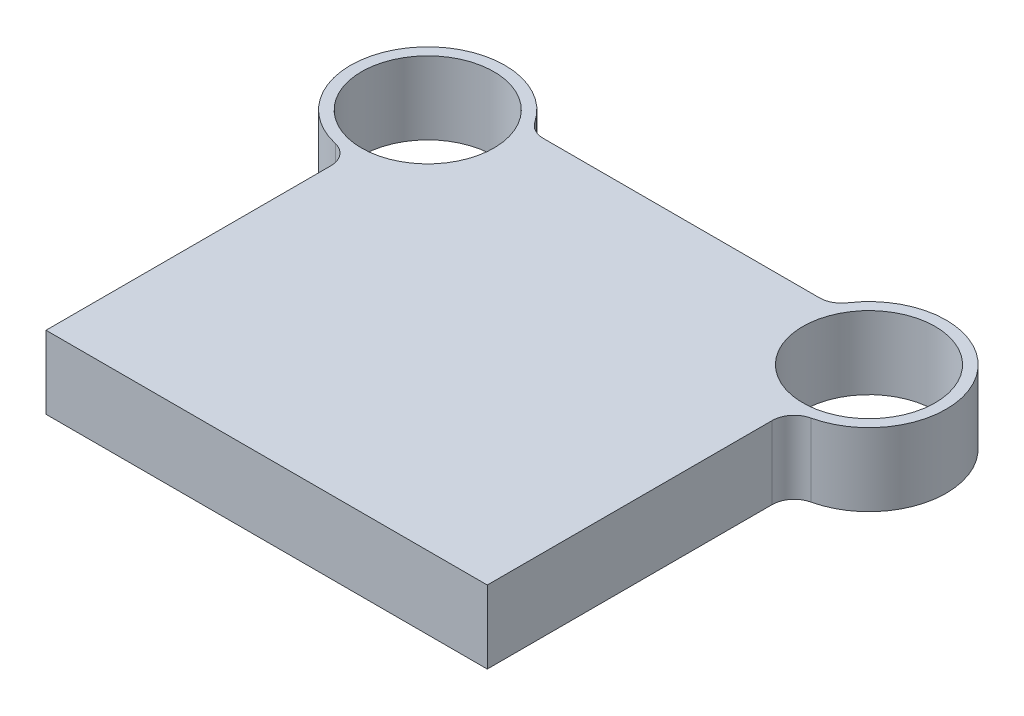
from build123d import *

# Parameters (mm, degrees)
SKETCH1_R           = 30
BOSS_EXTRUDE1_DEPTH = 33
FILLET1_R           = 10


with BuildPart() as part:
    # Sketch1 → Boss-Extrude1 (new body)
    with BuildSketch(Plane(origin=(0, 0, 0), x_dir=(1, 0, 0), z_dir=(0, 1, 0))):
        with BuildLine():
            Line((100, 0), (-100, 0))
            Line((-100, 0), (-100, 138))
            ThreePointArc((-100, 138), (-129.580398915, 191.708286934), (-68.377223398, 188))
            Line((-68.377223398, 188), (68.377223398, 188))
            ThreePointArc((68.377223398, 188), (129.580398915, 191.708286934), (100, 138))
            Line((100, 138), (100, 0))
        make_face()
        with Locations((-100, 173)):
            Circle(SKETCH1_R, mode=Mode.SUBTRACT)
        with Locations((100, 173)):
            Circle(SKETCH1_R, mode=Mode.SUBTRACT)
    extrude(amount=BOSS_EXTRUDE1_DEPTH)

    # Fillet1
    fillet1_edges = [part.edges().sort_by_distance(p)[0] for p in [
        (-100, 16.5, -138),
        (-68.377223398, 16.5, -188),
        (68.377223398, 16.5, -188),
        (100, 16.5, -138),
    ]]
    fillet(fillet1_edges, radius=FILLET1_R)


solid = part.part
